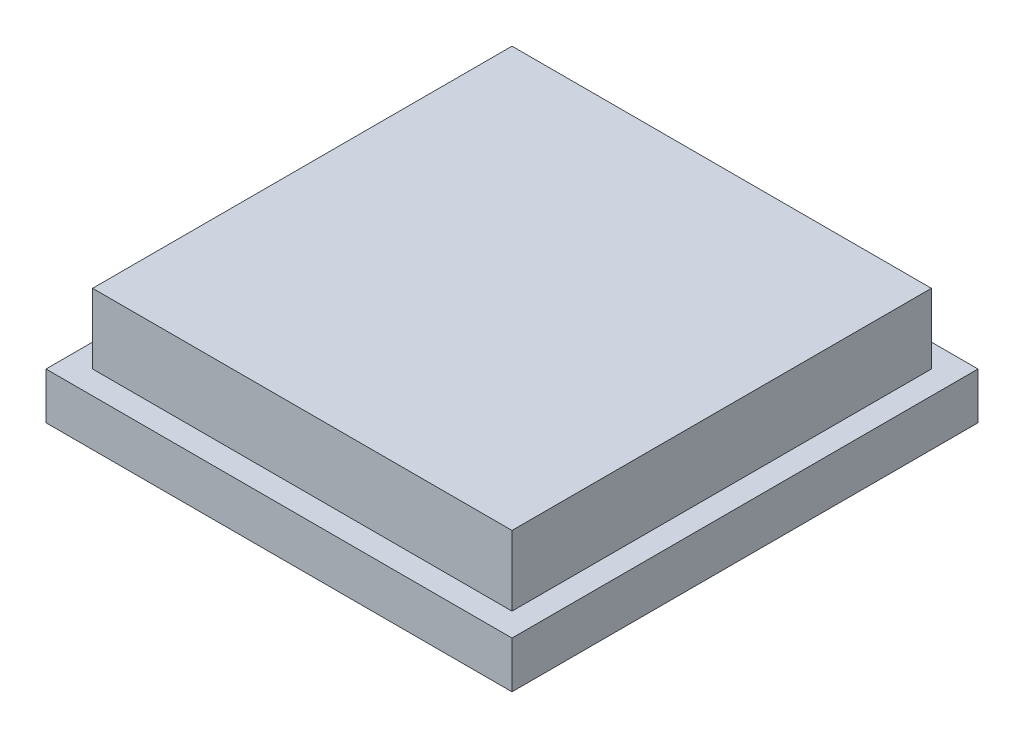
from build123d import *

# Parameters (mm, degrees)
SKETCH_1_W      = 10
SKETCH_1_H      = 10
EXTRUDE_1_DEPTH = 1
SKETCH_2_W      = 9
SKETCH_2_H      = 9
EXTRUDE_2_DEPTH = 2.5


with BuildPart() as part:
    # 草图1 → 凸台-拉伸1 (new body)
    with BuildSketch(Plane(origin=(0, 0, 0), x_dir=(1, 0, 0), z_dir=(0, 1, 0))):
        Rectangle(SKETCH_1_W, SKETCH_1_H)
    extrude(amount=EXTRUDE_1_DEPTH)

    # 草图2 → 凸台-拉伸2 (add)
    with BuildSketch(Plane(origin=(0, 0, 0), x_dir=(1, 0, 0), z_dir=(0, 1, 0))):
        Rectangle(SKETCH_2_W, SKETCH_2_H)
    extrude(amount=EXTRUDE_2_DEPTH)


solid = part.part
